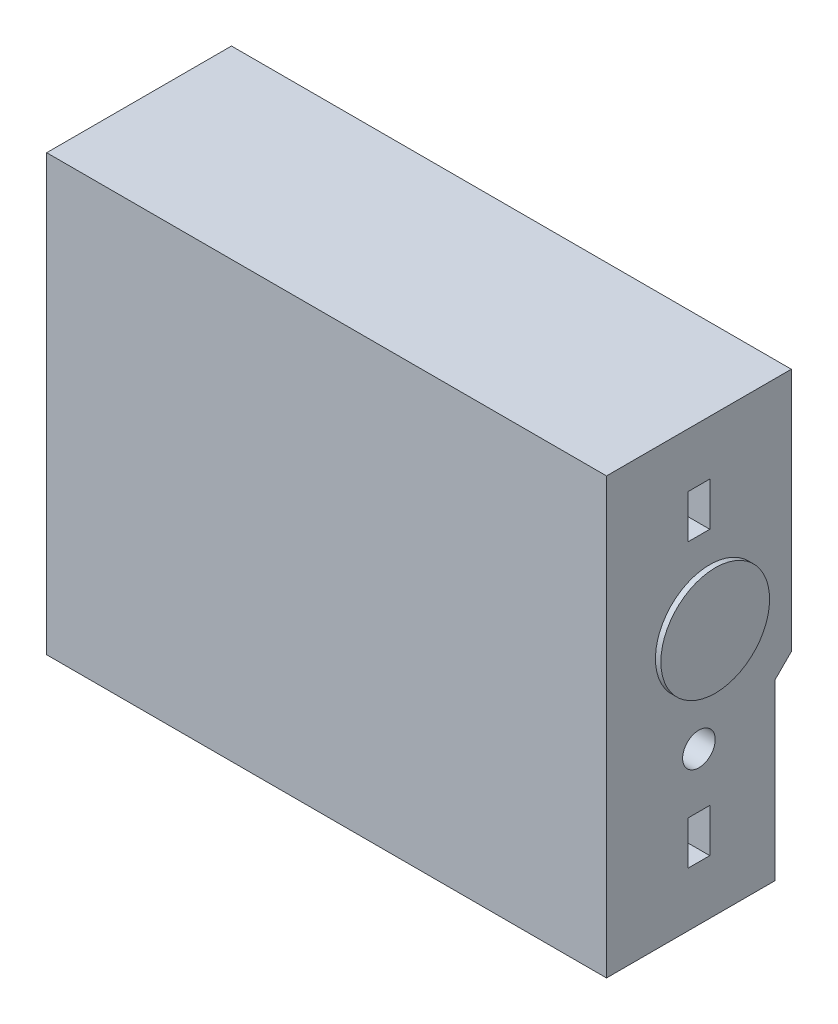
from build123d import *

# Parameters (mm, degrees)
ESQUISSE1_W             = 103
ESQUISSE1_H             = 80
BOSS_EXTRU_1_DEPTH      = 34
ENL_V_MAT_EXTRU_2_DEPTH = 224
ESQUISSE3_W             = 63.460243042
ESQUISSE3_H             = 20
ENL_V_MAT_EXTRU_3_DEPTH = 1
ESQUISSE4_R             = 4
BOSS_EXTRU_2_DEPTH      = 1
ESQUISSE5_R             = 3
ESQUISSE5_W             = 4
ESQUISSE5_H             = 8
ENL_V_MAT_EXTRU_4_DEPTH = 5
ESQUISSE6_R             = 10
BOSS_EXTRU_3_DEPTH      = 1
ESQUISSE7_W             = 8
ESQUISSE7_H             = 18
ESQUISSE7_W_2           = 4
ESQUISSE7_H_2           = 12
ENL_V_MAT_EXTRU_5_DEPTH = 5


with BuildPart() as part:
    # Esquisse1 → Boss.-Extru.1 (new body)
    with BuildSketch(Plane.XY):
        Rectangle(ESQUISSE1_W, ESQUISSE1_H)
    extrude(amount=BOSS_EXTRU_1_DEPTH)

    # Esquisse2 → Enlèv. mat.-Extru.2 (cut)
    with BuildSketch(Plane.ZY.offset(51.5)):
        Polygon((3, -8), (0, -5), (0, -40), (3, -40), (3, -37), align=None)
    extrude(amount=-ENL_V_MAT_EXTRU_2_DEPTH, mode=Mode.SUBTRACT)

    # Esquisse3 → Enlèv. mat.-Extru.3 (cut)
    with BuildSketch(Plane(origin=(0, 0, 0), x_dir=(-1, 0, 0), z_dir=(0, 0, -1))):
        with Locations((0, 17.5)):
            Rectangle(ESQUISSE3_W, ESQUISSE3_H)
    extrude(amount=-ENL_V_MAT_EXTRU_3_DEPTH, mode=Mode.SUBTRACT)

    # Esquisse4 → Boss.-Extru.2 (add)
    with BuildSketch(Plane(origin=(0, 0, 3), x_dir=(-1, 0, 0), z_dir=(0, 0, -1))):
        with Locations((-7.5, -20)):
            Circle(ESQUISSE4_R)
        with Locations((-22.5, -20)):
            Circle(ESQUISSE4_R)
        with Locations((7.5, -20)):
            Circle(ESQUISSE4_R)
        with Locations((22.5, -20)):
            Circle(ESQUISSE4_R)
    extrude(amount=BOSS_EXTRU_2_DEPTH)

    # Esquisse5 → Enlèv. mat.-Extru.4 (cut)
    with BuildSketch(Plane(origin=(51.5, 0, 0), x_dir=(0, 0, -1), z_dir=(1, 0, 0))):
        with Locations((-17, -12)):
            Circle(ESQUISSE5_R)
        with Locations((-17, 26)):
            Rectangle(ESQUISSE5_W, ESQUISSE5_H)
        with Locations((-17, -26)):
            Rectangle(ESQUISSE5_W, ESQUISSE5_H)
    extrude(amount=-ENL_V_MAT_EXTRU_4_DEPTH, mode=Mode.SUBTRACT)

    # Esquisse6 → Boss.-Extru.3 (add)
    with BuildSketch(Plane(origin=(51.5, 0, 0), x_dir=(0, 0, -1), z_dir=(1, 0, 0))):
        with Locations((-15, 6.367248466)):
            Circle(ESQUISSE6_R)
    extrude(amount=BOSS_EXTRU_3_DEPTH)

    # Esquisse7 → Enlèv. mat.-Extru.5 (cut)
    with BuildSketch(Plane.ZY.offset(51.5)):
        with Locations((18.106114865, -18.992792822)):
            Rectangle(ESQUISSE7_W, ESQUISSE7_H)
        with Locations((19.212725932, 22.654616942)):
            Rectangle(ESQUISSE7_W_2, ESQUISSE7_H_2)
    extrude(amount=-ENL_V_MAT_EXTRU_5_DEPTH, mode=Mode.SUBTRACT)


solid = part.part
